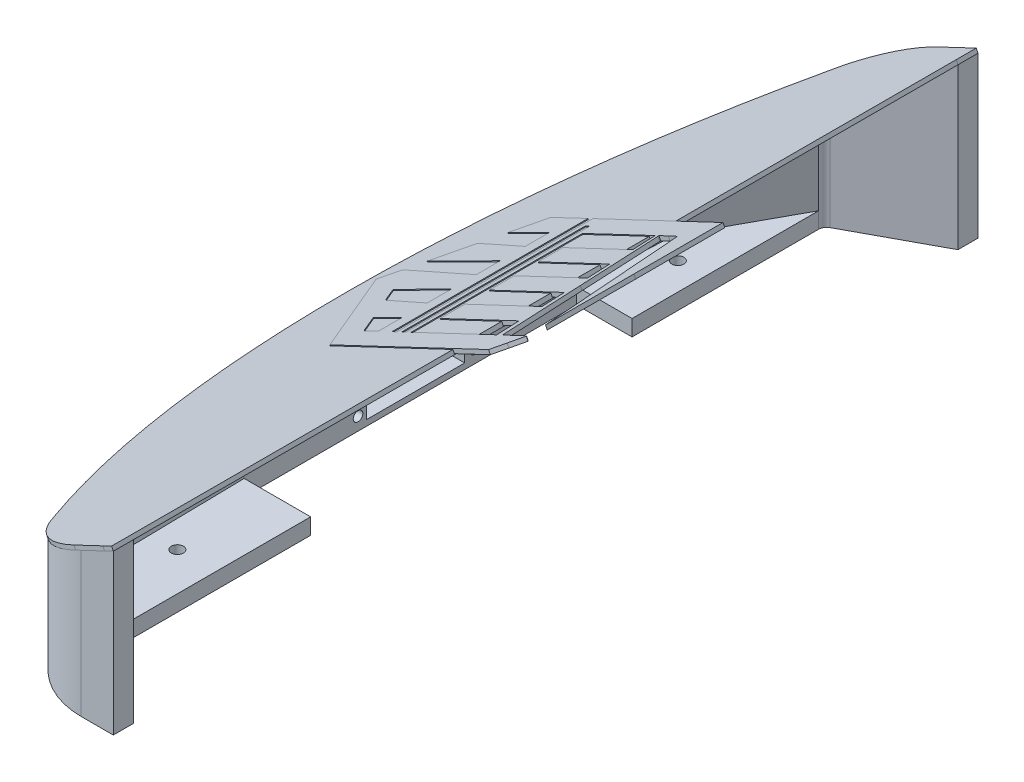
from build123d import *

# Parameters (mm, degrees)
FRONT_SKETCH_R      = 1.905
BOSS_EXTRUDE1_DEPTH = 50.8
CUT_EXTRUDE1_DEPTH  = 45.72
CUT_EXTRUDE2_DEPTH  = 320.68422056
CUT_EXTRUDE3_DEPTH  = 159.197793465
SKETCH6_W           = 6.524310643
SKETCH6_H           = 22.300846009
SKETCH6_R           = 1.524
SKETCH6_W_2         = 6.962786951
BOSS_EXTRUDE2_DEPTH = 10.16
SKETCH9_W           = 6.962786951
SKETCH9_H           = 7.327254738
SKETCH9_W_2         = 6.524310643
BOSS_EXTRUDE3_DEPTH = 7.62
SKETCH10_R          = 1.524
CUT_EXTRUDE4_DEPTH  = 165.174187853
BOSS_EXTRUDE5_DEPTH = 1.27
BOSS_EXTRUDE6_DEPTH = 1.27


with BuildPart() as part:
    # front_sketch → Boss-Extrude1 (new body)
    with BuildSketch(Plane(origin=(0, 0, 0), x_dir=(1, 0, 0), z_dir=(0, 1, 0))):
        with BuildLine():
            Line((-94.961375831, 124.478458264), (-121.345326632, 110.234521439))
            ThreePointArc((-121.345326632, 110.234521439), (-122.32001306, 109.300728329), (-122.678671172, 107.99944144))
            Line((-122.678671172, 107.99944144), (-122.678671172, 48.810796684))
            Line((-122.678671172, 48.810796684), (-140.250849959, 48.810796684))
            Line((-140.250849959, 48.810796684), (-140.250849959, -56.645199257))
            Line((-140.250849959, -56.645199257), (-119.167015715, -56.645199257))
            Line((-119.167015715, -56.645199257), (-119.167015715, -126.112255785))
            Line((-119.167015715, -126.112255785), (-95.601645083, -136.460242597))
            Line((-95.601645083, -136.460242597), (-95.601645083, -142.810242597))
            Line((-95.601645083, -142.810242597), (-105.798207048, -142.810242597))
            ThreePointArc((-105.798207048, -142.810242597), (-119.167015715, -139.007347839), (-128.532661201, -128.737404395))
            ThreePointArc((-128.532661201, -128.737404395), (-157.286213724, -5.861503432), (-127.918775374, 116.869125935))
            ThreePointArc((-127.918775374, 116.869125935), (-118.556014486, 127.058910858), (-105.241228699, 130.828458264))
            Line((-105.241228699, 130.828458264), (-94.961375831, 130.828458264))
            Line((-94.961375831, 130.828458264), (-94.961375831, 124.478458264))
        make_face()
        with Locations(Location((-131.296368682, 71.963600743, 0), (0, 0, 270))):
            Circle(FRONT_SKETCH_R, mode=Mode.SUBTRACT)
        with Locations(Location((-131.296368682, -86.786399257, 0), (0, 0, 270))):
            Circle(FRONT_SKETCH_R, mode=Mode.SUBTRACT)
    extrude(amount=BOSS_EXTRUDE1_DEPTH)

    # Sketch1 → Cut-Extrude1 (cut)
    with BuildSketch(Plane(origin=(0, 50.8, 0), x_dir=(1, 0, 0), z_dir=(0, 1, 0))):
        Polygon((-122.678671172, 48.810796684), (-122.678671172, 107.99944144), (-138.833286115, 78.405119062), (-140.250849959, 48.810796684), align=None)
        Polygon((-119.167015715, -56.645199257), (-140.250849959, -56.645199257), (-139.542068037, -96.192486205), (-119.167015715, -126.112255785), align=None)
    extrude(amount=-CUT_EXTRUDE1_DEPTH, mode=Mode.SUBTRACT)

    # Sketch3 → Cut-Extrude2 (cut, through all)
    with BuildSketch(Plane.XY.offset(142.810242597)):
        Polygon((-94.961375831, 50.8), (-157.287069608, 21.270817167), (-157.287069608, 50.8), align=None)
    extrude(amount=-CUT_EXTRUDE2_DEPTH, mode=Mode.SUBTRACT)

    # Sketch4 → Cut-Extrude3 (cut, through all)
    with BuildSketch(Plane(origin=(-140.250849959, 0, 0), x_dir=(0, 0, -1), z_dir=(1, 0, 0))):
        Polygon((-24.404629664, 24.144542412), (20.256333242, 24.144542412), (20.256333242, 5.094542412), (20.256333242, 1.843696403), (-24.404629664, 1.843696403), (-24.404629664, 5.094542412), align=None)
    extrude(amount=-CUT_EXTRUDE3_DEPTH, mode=Mode.SUBTRACT)

    # Sketch6 → Boss-Extrude2 (add)
    with BuildSketch(Plane(origin=(-140.250849959, 0, 0), x_dir=(0, 0, -1), z_dir=(1, 0, 0))):
        with Locations((-21.142474343, 12.994119407)):
            Rectangle(SKETCH6_W, SKETCH6_H)
        with Locations(Location((-20.530013168, 4.101512488, 0), (0, 0, 180))):
            Circle(SKETCH6_R, mode=Mode.SUBTRACT)
        with Locations((16.774939767, 12.994119407)):
            Rectangle(SKETCH6_W_2, SKETCH6_H)
        with Locations((16.553986832, 4.101512488)):
            Circle(SKETCH6_R, mode=Mode.SUBTRACT)
    extrude(amount=-BOSS_EXTRUDE2_DEPTH)

    # Sketch9 → Boss-Extrude3 (add)
    with BuildSketch(Plane.ZY.offset(150.410849959)):
        with Locations((-16.774939767, 5.507323772)):
            Rectangle(SKETCH9_W, SKETCH9_H)
        with Locations((21.142474343, 5.507323772)):
            Rectangle(SKETCH9_W_2, SKETCH9_H)
    extrude(amount=BOSS_EXTRUDE3_DEPTH)

    # Sketch10 → Cut-Extrude4 (cut, through all)
    with BuildSketch(Plane.ZY.offset(158.030849959)):
        with Locations(Location((-16.553986832, 4.101512488, 0), (0, 0, 180))):
            Circle(SKETCH10_R)
        with Locations((20.530013168, 4.101512488)):
            Circle(SKETCH10_R)
    extrude(amount=-CUT_EXTRUDE4_DEPTH, mode=Mode.SUBTRACT)

    # Sketch8 → Boss-Extrude5 (add)
    with BuildSketch(Plane(origin=(-37.06479765, 78.230719803, 0), x_dir=(0.9037014530109695, 0.4281631509434955, 0), z_dir=(-0.4281631509434955, 0.9037014530109695, 0))):
        with BuildLine():
            Line((-67.153667142, 130.805409433), (-64.066045251, 130.828458264))
            Line((-64.066045251, 130.828458264), (-64.066045251, 124.478458264))
            Line((-64.066045251, 124.478458264), (-64.77454168, -142.810242597))
            Line((-64.77454168, -142.810242597), (-67.793936395, -142.833291428))
            Line((-67.793936395, -142.833291428), (-77.990498359, -142.833291428))
            ThreePointArc((-77.990498359, -142.833291428), (-91.359307026, -139.03039667), (-100.724952512, -128.760453226))
            ThreePointArc((-100.724952512, -128.760453226), (-133.122421018, -5.875444409), (-100.111066685, 116.846077105))
            ThreePointArc((-100.111066685, 116.846077105), (-90.748305797, 127.035862027), (-77.43352001, 130.805409433))
            Line((-77.43352001, 130.805409433), (-67.153667142, 130.805409433))
        make_face()
    extrude(amount=BOSS_EXTRUDE5_DEPTH)

    # logo → Boss-Extrude6 (add)
    with BuildSketch(Plane(origin=(-37.17355109, 78.460259972, 0), x_dir=(0.9037014530109694, 0.4281631509434959, 0), z_dir=(-0.4281631509434959, 0.9037014530109694, 0))):
        with BuildLine():
            Line((-99.668225952, 4.11534864), (-99.219179352, 4.1104566))
            Line((-99.219179352, 4.1104566), (-99.219179352, 7.939278))
            add(Edge.make_bspline(
                [(-99.219179352, 7.939278), (-99.219179352, 10.0451412), (-99.251061432, 11.7692424), (-99.290075832, 11.77056828)],
                knots=[0, 0, 0, 0, 1, 1, 1, 1], degree=3))
            add(Edge.make_bspline(
                [(-99.290075832, 11.77056828), (-99.329090232, 11.77056828), (-104.753951112, 11.44633728), (-111.345373032, 11.04730836)],
                knots=[0, 0, 0, 0, 1, 1, 1, 1], degree=3))
            add(Edge.make_bspline(
                [(-111.345373032, 11.04730836), (-117.936779712, 10.6483404), (-123.350835432, 10.34267172), (-123.376606272, 10.36844256)],
                knots=[0, 0, 0, 0, 1, 1, 1, 1], degree=3))
            add(Edge.make_bspline(
                [(-123.376606272, 10.36844256), (-123.421122312, 10.41240996), (-117.176623752, 20.20311936), (-116.956085712, 20.4344778)],
                knots=[0, 0, 0, 0, 1, 1, 1, 1], degree=3))
            add(Edge.make_bspline(
                [(-116.956085712, 20.4344778), (-116.875801392, 20.51855688), (-114.949434912, 20.44546584), (-108.862182672, 20.1338688)],
                knots=[0, 0, 0, 0, 1, 1, 1, 1], degree=3))
            add(Edge.make_bspline(
                [(-108.862182672, 20.1338688), (-104.468460192, 19.908012), (-100.501366272, 19.69698372), (-100.046391312, 19.66565028)],
                knots=[0, 0, 0, 0, 1, 1, 1, 1], degree=3))
            Line((-100.046391312, 19.66565028), (-99.219164112, 19.60795164))
            Line((-99.219164112, 19.60795164), (-99.219164112, 23.47583316))
            Line((-99.219164112, 23.47583316), (-99.219164112, 27.34372992))
            Line((-99.219164112, 27.34372992), (-99.620951472, 27.30526416))
            add(Edge.make_bspline(
                [(-99.620951472, 27.30526416), (-100.753268232, 27.20138832), (-112.947676152, 26.50347252), (-112.984922712, 26.54067336)],
                knots=[0, 0, 0, 0, 1, 1, 1, 1], degree=3))
            add(Edge.make_bspline(
                [(-112.984922712, 26.54067336), (-113.023388472, 26.57913912), (-107.799726072, 34.75576488), (-107.527372032, 35.084004)],
                knots=[0, 0, 0, 0, 1, 1, 1, 1], degree=3))
            add(Edge.make_bspline(
                [(-107.527372032, 35.084004), (-107.439604872, 35.18952576), (-106.276350912, 35.21205048), (-100.909280112, 35.21205048)],
                knots=[0, 0, 0, 0, 1, 1, 1, 1], degree=3))
            Line((-100.909280112, 35.21205048), (-94.397654832, 35.21205048))
            Line((-94.397654832, 35.21205048), (-94.397654832, 4.10865828))
            Line((-94.397654832, 4.10865828), (-94.397654832, -26.99481012))
            Line((-94.397654832, -26.99481012), (-93.546805632, -26.99481012))
            Line((-93.546805632, -26.99481012), (-92.695941192, -26.99481012))
            Line((-92.695941192, -26.99481012), (-92.695941192, 4.10865828))
            Line((-92.695941192, 4.10865828), (-92.695941192, 35.21205048))
            Line((-92.695941192, 35.21205048), (-69.864714312, 35.21205048))
            Line((-69.864714312, 35.21205048), (-47.033472192, 35.21205048))
            Line((-47.033472192, 35.21205048), (-47.046106152, 6.96844428))
            add(Edge.make_bspline(
                [(-47.046106152, 6.96844428), (-47.053253712, -8.56553532), (-47.077988232, -21.1688172), (-47.100512952, -21.03880476)],
                knots=[0, 0, 0, 0, 1, 1, 1, 1], degree=3))
            add(Edge.make_bspline(
                [(-47.100512952, -21.03880476), (-47.177566392, -20.60300172), (-54.217958712, 27.19193952), (-54.217958712, 27.27915804)],
                knots=[0, 0, 0, 0, 1, 1, 1, 1], degree=3))
            add(Edge.make_bspline(
                [(-54.217958712, 27.27915804), (-54.217958712, 27.32861184), (-55.603046112, 27.36543168), (-57.535142832, 27.36543168)],
                knots=[0, 0, 0, 0, 1, 1, 1, 1], degree=3))
            Line((-57.535142832, 27.36543168), (-60.852326952, 27.36543168))
            Line((-60.852326952, 27.36543168), (-60.798484032, 27.01097976))
            add(Edge.make_bspline(
                [(-60.798484032, 27.01097976), (-60.768796512, 26.81589252), (-59.614717032, 14.68064628), (-58.233652992, 0.0435864)],
                knots=[0, 0, 0, 0, 1, 1, 1, 1], degree=3))
            add(Edge.make_bspline(
                [(-58.233652992, 0.0435864), (-56.852604192, -14.59341252), (-55.702334712, -26.66490984), (-55.677523992, -26.78190732)],
                knots=[0, 0, 0, 0, 1, 1, 1, 1], degree=3))
            Line((-55.677523992, -26.78190732), (-55.632459312, -26.99458152))
            Line((-55.632459312, -26.99458152), (-51.332721912, -26.99458152))
            add(Edge.make_bspline(
                [(-51.332721912, -26.99458152), (-47.194726632, -26.99458152), (-47.032984512, -27.00008316), (-47.032984512, -27.1715484)],
                knots=[0, 0, 0, 0, 1, 1, 1, 1], degree=3))
            add(Edge.make_bspline(
                [(-47.032984512, -27.1715484), (-47.032984512, -27.26881008), (-48.111458352, -29.02368084), (-49.429596432, -31.07125104)],
                knots=[0, 0, 0, 0, 1, 1, 1, 1], degree=3))
            Line((-49.429596432, -31.07125104), (-51.826208352, -34.79410872))
            Line((-51.826208352, -34.79410872), (-79.667905272, -34.8160848))
            Line((-79.667905272, -34.8160848), (-107.509602192, -34.83807612))
            Line((-107.509602192, -34.83807612), (-118.649859312, -17.51354892))
            add(Edge.make_bspline(
                [(-118.649859312, -17.51354892), (-124.776994632, -7.98510468), (-129.840804672, -0.10396728), (-129.902770512, 0)],
                knots=[0, 0, 0, 0, 1, 1, 1, 1], degree=3))
            add(Edge.make_bspline(
                [(-129.902770512, 0), (-130.002287712, 0.16707612), (-129.823354872, 0.48690276), (-128.368087272, 2.74164552)],
                knots=[0, 0, 0, 0, 1, 1, 1, 1], degree=3))
            Line((-128.368087272, 2.74164552), (-128.368559712, 2.73978624))
            add(Edge.make_bspline(
                [(-128.368559712, 2.73978624), (-127.462526472, 4.14371028), (-126.670046472, 5.33881584), (-126.607486272, 5.39569152)],
                knots=[0, 0, 0, 0, 1, 1, 1, 1], degree=3))
            add(Edge.make_bspline(
                [(-126.607486272, 5.39569152), (-126.524946432, 5.47042848), (-122.878014432, 5.30996652), (-113.305511352, 4.80954588)],
                knots=[0, 0, 0, 0, 1, 1, 1, 1], degree=3))
            add(Edge.make_bspline(
                [(-113.305511352, 4.80954588), (-106.051987632, 4.43035944), (-99.915205392, 4.11793944), (-99.668225952, 4.11534864)],
                knots=[0, 0, 0, 0, 1, 1, 1, 1], degree=3))
        make_face()
        with BuildLine():
            Line((-72.659562672, -26.99282892), (-57.633760872, -26.99282892))
            Line((-57.633760872, -26.99282892), (-57.675533712, -26.68563624))
            add(Edge.make_bspline(
                [(-57.675533712, -26.68563624), (-57.698607072, -26.5169142), (-57.824123712, -25.01703912), (-57.954425712, -23.35312068)],
                knots=[0, 0, 0, 0, 1, 1, 1, 1], degree=3))
            add(Edge.make_bspline(
                [(-57.954425712, -23.35312068), (-58.084666752, -21.68924796), (-58.216888992, -20.10456228), (-58.248207192, -19.83155292)],
                knots=[0, 0, 0, 0, 1, 1, 1, 1], degree=3))
            Line((-58.248207192, -19.83155292), (-58.305143832, -19.33530804))
            Line((-58.305143832, -19.33530804), (-72.144252552, -19.33530804))
            Line((-72.144252552, -19.33530804), (-85.983376512, -19.33530804))
            Line((-85.983376512, -19.33530804), (-85.983376512, -15.41192244))
            Line((-85.983376512, -15.41192244), (-85.983376512, -11.4885216))
            Line((-85.983376512, -11.4885216), (-72.464262072, -11.4885216))
            Line((-72.464262072, -11.4885216), (-58.945132392, -11.4885216))
            Line((-58.945132392, -11.4885216), (-58.951731312, -11.18132892))
            add(Edge.make_bspline(
                [(-58.951731312, -11.18132892), (-58.955434632, -11.01207348), (-59.093676672, -9.27873684), (-59.258984952, -7.32882456)],
                knots=[0, 0, 0, 0, 1, 1, 1, 1], degree=3))
            Line((-59.258984952, -7.32882456), (-59.559472032, -3.7836348))
            Line((-59.559472032, -3.7836348), (-72.771348072, -3.76165872))
            Line((-72.771348072, -3.76165872), (-85.983208872, -3.7396674))
            Line((-85.983208872, -3.7396674), (-85.983208872, 0.1833372))
            Line((-85.983208872, 0.1833372), (-85.983208872, 4.10640276))
            Line((-85.983208872, 4.10640276), (-73.080857232, 4.10640276))
            Line((-73.080857232, 4.10640276), (-60.178048392, 4.10640276))
            Line((-60.178048392, 4.10640276), (-60.225307632, 4.50811392))
            add(Edge.make_bspline(
                [(-60.225307632, 4.50811392), (-60.251139432, 4.72903296), (-60.378362952, 6.27129048), (-60.507826752, 7.9351632)],
                knots=[0, 0, 0, 0, 1, 1, 1, 1], degree=3))
            add(Edge.make_bspline(
                [(-60.507826752, 7.9351632), (-60.637366752, 9.59908164), (-60.766891512, 11.14121724), (-60.795634152, 11.36219724)],
                knots=[0, 0, 0, 0, 1, 1, 1, 1], degree=3))
            Line((-60.795634152, 11.36219724), (-60.847846392, 11.76392364))
            Line((-60.847846392, 11.76392364), (-73.415771472, 11.76392364))
            Line((-73.415771472, 11.76392364), (-85.983711792, 11.76392364))
            Line((-85.983711792, 11.76392364), (-85.983711792, 15.68730924))
            Line((-85.983711792, 15.68730924), (-85.983711792, 19.61064912))
            Line((-85.983711792, 19.61064912), (-73.740871152, 19.61064912))
            Line((-73.740871152, 19.61064912), (-61.498030512, 19.61064912))
            Line((-61.498030512, 19.61064912), (-61.498030512, 19.8502524))
            add(Edge.make_bspline(
                [(-61.498030512, 19.8502524), (-61.498030512, 20.25086628), (-62.069103792, 27.1179798), (-62.112949272, 27.24463944)],
                knots=[0, 0, 0, 0, 1, 1, 1, 1], degree=3))
            add(Edge.make_bspline(
                [(-62.112949272, 27.24463944), (-62.145379992, 27.33860928), (-64.779263472, 27.36279516), (-74.856622032, 27.36279516)],
                knots=[0, 0, 0, 0, 1, 1, 1, 1], degree=3))
            add(Edge.make_bspline(
                [(-74.856622032, 27.36279516), (-81.843125712, 27.36279516), (-87.587721792, 27.33531744), (-87.622392792, 27.29959488)],
                knots=[0, 0, 0, 0, 1, 1, 1, 1], degree=3))
            add(Edge.make_bspline(
                [(-87.622392792, 27.29959488), (-87.657002832, 27.26663076), (-87.685425432, 15.03389424), (-87.685425432, 0.11952732)],
                knots=[0, 0, 0, 0, 1, 1, 1, 1], degree=3))
            Line((-87.685425432, 0.11952732), (-87.685425432, -26.99744664))
            Line((-87.685425432, -26.99744664), (-72.659562672, -26.99282892))
        make_face(mode=Mode.SUBTRACT)
        Polygon((-90.190652832, -26.99282892), (-89.387062872, -26.99282892), (-89.387062872, 2.07801972), (-89.387062872, 31.14885312), (-90.190652832, 31.14885312), (-90.994242792, 31.14885312), (-90.994242792, 2.07801972), (-90.994242792, -26.99282892), align=None, mode=Mode.SUBTRACT)
        with BuildLine():
            Line((-106.381598352, -23.68393536), (-104.272001352, -26.94550872))
            Line((-104.272001352, -26.94550872), (-101.745575112, -26.97298644))
            Line((-101.745575112, -26.97298644), (-99.219164112, -27.00046416))
            Line((-99.219164112, -27.00046416), (-99.219164112, -23.1700578))
            Line((-99.219164112, -23.1700578), (-99.219164112, -19.33965144))
            Line((-99.219164112, -19.33965144), (-99.468216192, -19.33965144))
            add(Edge.make_bspline(
                [(-99.468216192, -19.33965144), (-99.847890312, -19.33965144), (-107.503765272, -19.80236832), (-108.175376832, -19.86611724)],
                knots=[0, 0, 0, 0, 1, 1, 1, 1], degree=3))
            Line((-108.175376832, -19.86611724), (-108.764860032, -19.92162132))
            Line((-108.764860032, -19.92162132), (-108.628020072, -20.17442244))
            add(Edge.make_bspline(
                [(-108.628020072, -20.17442244), (-108.552734472, -20.31345696), (-107.541865272, -21.8947746), (-106.381598352, -23.688675)],
                knots=[0, 0, 0, 0, 1, 1, 1, 1], degree=3))
            Line((-106.381598352, -23.688675), (-106.381598352, -23.68393536))
        make_face(mode=Mode.SUBTRACT)
        with BuildLine():
            Line((-116.331032352, -8.21041284), (-114.771462192, -10.6297476))
            Line((-114.771462192, -10.6297476), (-114.298473552, -10.6792014))
            add(Edge.make_bspline(
                [(-114.298473552, -10.6792014), (-114.038311512, -10.70667912), (-110.783672352, -10.87814436), (-107.065920072, -11.06059764)],
                knots=[0, 0, 0, 0, 1, 1, 1, 1], degree=3))
            add(Edge.make_bspline(
                [(-107.065920072, -11.06059764), (-103.348152552, -11.24303568), (-100.061737992, -11.41614684), (-99.762759672, -11.44472184)],
                knots=[0, 0, 0, 0, 1, 1, 1, 1], degree=3))
            Line((-99.762759672, -11.44472184), (-99.219148872, -11.49967728))
            Line((-99.219148872, -11.49967728), (-99.219148872, -7.61311152))
            Line((-99.219148872, -7.61311152), (-99.219148872, -3.7264848))
            Line((-99.219148872, -3.7264848), (-99.620920992, -3.7759386))
            add(Edge.make_bspline(
                [(-99.620920992, -3.7759386), (-99.841885752, -3.80341632), (-104.106799752, -4.06665684), (-109.098478872, -4.35885336)],
                knots=[0, 0, 0, 0, 1, 1, 1, 1], degree=3))
            add(Edge.make_bspline(
                [(-109.098478872, -4.35885336), (-114.090157992, -4.65120228), (-118.228168512, -4.90564932), (-118.294066272, -4.92515652)],
                knots=[0, 0, 0, 0, 1, 1, 1, 1], degree=3))
            add(Edge.make_bspline(
                [(-118.294066272, -4.92515652), (-118.431226272, -4.96362228), (-118.532511312, -4.79546412), (-116.331032352, -8.21041284)],
                knots=[0, 0, 0, 0, 1, 1, 1, 1], degree=3))
        make_face(mode=Mode.SUBTRACT)
    extrude(amount=BOSS_EXTRUDE6_DEPTH)


solid = part.part
